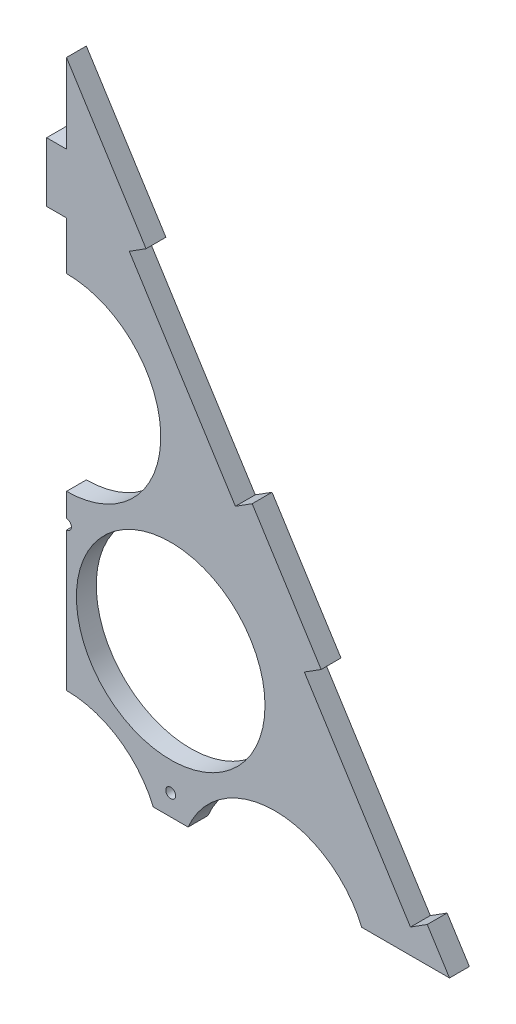
from build123d import *

# Parameters (mm, degrees)
ESQUISSE1_R             = 47.5
BOSS_EXTRU_1_DEPTH      = 10
ESQUISSE3_W             = 100
ESQUISSE3_H             = 10
ENL_V_MAT_EXTRU_1_DEPTH = 11
ESQUISSE4_R             = 2.5
ENL_V_MAT_EXTRU_2_DEPTH = 11
ESQUISSE6_W             = 150
ESQUISSE6_H             = 120
BOSS_EXTRU_2_DEPTH      = 10
ESQUISSE7_W             = 10
ESQUISSE7_H             = 50
ESQUISSE7_W_2           = 50
ESQUISSE7_H_2           = 9.570800355
ENL_V_MAT_EXTRU_3_DEPTH = 10
ENL_V_MAT_EXTRU_5_DEPTH = 10
ESQUISSE11_W            = 10
ESQUISSE11_H            = 30
BOSS_EXTRU_4_DEPTH      = 10


with BuildPart() as part:
    # Esquisse1 → Boss.-Extru.1 (new body)
    with BuildSketch(Plane.XY):
        Polygon((-310, -75.642859016), (0, 414.561180135), (310, -75.642859016), align=None)
        with Locations((-157.5, 0)):
            Circle(ESQUISSE1_R, mode=Mode.SUBTRACT)
        with Locations((-52.5, 0)):
            Circle(ESQUISSE1_R, mode=Mode.SUBTRACT)
        with Locations((52.5, 0)):
            Circle(ESQUISSE1_R, mode=Mode.SUBTRACT)
        with Locations((157.5, 0)):
            Circle(ESQUISSE1_R, mode=Mode.SUBTRACT)
        with Locations((-105, 90.932667397)):
            Circle(ESQUISSE1_R, mode=Mode.SUBTRACT)
        with Locations((0, 90.932667397)):
            Circle(ESQUISSE1_R, mode=Mode.SUBTRACT)
        with Locations((105, 90.932667397)):
            Circle(ESQUISSE1_R, mode=Mode.SUBTRACT)
        with Locations((-52.5, 181.865334795)):
            Circle(ESQUISSE1_R, mode=Mode.SUBTRACT)
        with Locations((52.5, 181.865334795)):
            Circle(ESQUISSE1_R, mode=Mode.SUBTRACT)
        with Locations((0, 272.798002192)):
            Circle(ESQUISSE1_R, mode=Mode.SUBTRACT)
    extrude(amount=BOSS_EXTRU_1_DEPTH)

    # Esquisse3 → Enlèv. mat.-Extru.1 (cut, through all)
    with BuildSketch(Plane.XY.offset(10)):
        Polygon((-269.913793103, -12.254405678), (-261.461999325, -17.599233264), (-208.013723463, 66.918704521), (-216.465517241, 72.263532107), align=None)
        Polygon((-181.724137931, 127.200191667), (-173.272344153, 121.855364081), (-119.82406829, 206.373301865), (-128.275862069, 211.718129452), align=None)
        Polygon((-93.534482759, 266.654789012), (-85.08268898, 261.309961425), (-31.634413118, 345.82789921), (-40.086206897, 351.172726796), align=None)
        Polygon((269.913793103, -12.254405678), (261.461999325, -17.599233264), (208.013723463, 66.918704521), (216.465517241, 72.263532107), align=None)
        Polygon((181.724137931, 127.200191667), (173.272344153, 121.855364081), (119.82406829, 206.373301865), (128.275862069, 211.718129452), align=None)
        Polygon((93.534482759, 266.654789012), (85.08268898, 261.309961425), (31.634413118, 345.82789921), (40.086206897, 351.172726796), align=None)
        with Locations((-160, -70.642859016)):
            Rectangle(ESQUISSE3_W, ESQUISSE3_H)
        with Locations((160, -70.642859016)):
            Rectangle(ESQUISSE3_W, ESQUISSE3_H)
    extrude(amount=-ENL_V_MAT_EXTRU_1_DEPTH, mode=Mode.SUBTRACT)

    # Esquisse4 → Enlèv. mat.-Extru.2 (cut, through all)
    with BuildSketch(Plane.XY.offset(10)):
        with Locations((-157.5, -55.642859016)):
            Circle(ESQUISSE4_R)
        with Locations((-52.5, -55.642859016)):
            Circle(ESQUISSE4_R)
        with Locations((52.5, -55.642859016)):
            Circle(ESQUISSE4_R)
        with Locations((157.5, -55.642859016)):
            Circle(ESQUISSE4_R)
        with Locations((-105, 29.047375097)):
            Circle(ESQUISSE4_R)
        with Locations((0, 29.047375097)):
            Circle(ESQUISSE4_R)
        with Locations((105, 29.047375097)):
            Circle(ESQUISSE4_R)
        with Locations((-52.5, 119.980042494)):
            Circle(ESQUISSE4_R)
        with Locations((52.5, 119.980042494)):
            Circle(ESQUISSE4_R)
        with Locations((0, 210.912709891)):
            Circle(ESQUISSE4_R)
    extrude(amount=-ENL_V_MAT_EXTRU_2_DEPTH, mode=Mode.SUBTRACT)

    # Esquisse6 → Boss.-Extru.2 (add)
    with BuildSketch(Plane.XY.offset(10)):
        with Locations((0, -135.642859016)):
            Rectangle(ESQUISSE6_W, ESQUISSE6_H)
    extrude(amount=-BOSS_EXTRU_2_DEPTH)

    # Esquisse7 → Enlèv. mat.-Extru.3 (cut)
    with BuildSketch(Plane.XY.offset(10)):
        with Locations((-70, -135.642859016)):
            Rectangle(ESQUISSE7_W, ESQUISSE7_H)
        with Locations((0, -190.857458839)):
            Rectangle(ESQUISSE7_W_2, ESQUISSE7_H_2)
        with Locations((70, -135.642859016)):
            Rectangle(ESQUISSE7_W, ESQUISSE7_H)
    extrude(amount=-ENL_V_MAT_EXTRU_3_DEPTH, mode=Mode.SUBTRACT)

    # Esquisse10 → Enlèv. mat.-Extru.5 (cut)
    with BuildSketch(Plane.XY.offset(10)):
        Polygon((0, 414.561180135), (0, 109.461180135), (337.106568203, 109.461180135), (337.106568203, -228.052583807), (-388.969117157, -228.052583807), (-388.969117157, 414.561180135), align=None)
    extrude(amount=-ENL_V_MAT_EXTRU_5_DEPTH, mode=Mode.SUBTRACT)

    # Esquisse11 → Boss.-Extru.4 (add)
    with BuildSketch(Plane.XY.offset(10)):
        with Locations((-5, 359.561180135)):
            Rectangle(ESQUISSE11_W, ESQUISSE11_H)
    extrude(amount=-BOSS_EXTRU_4_DEPTH)


solid = part.part
